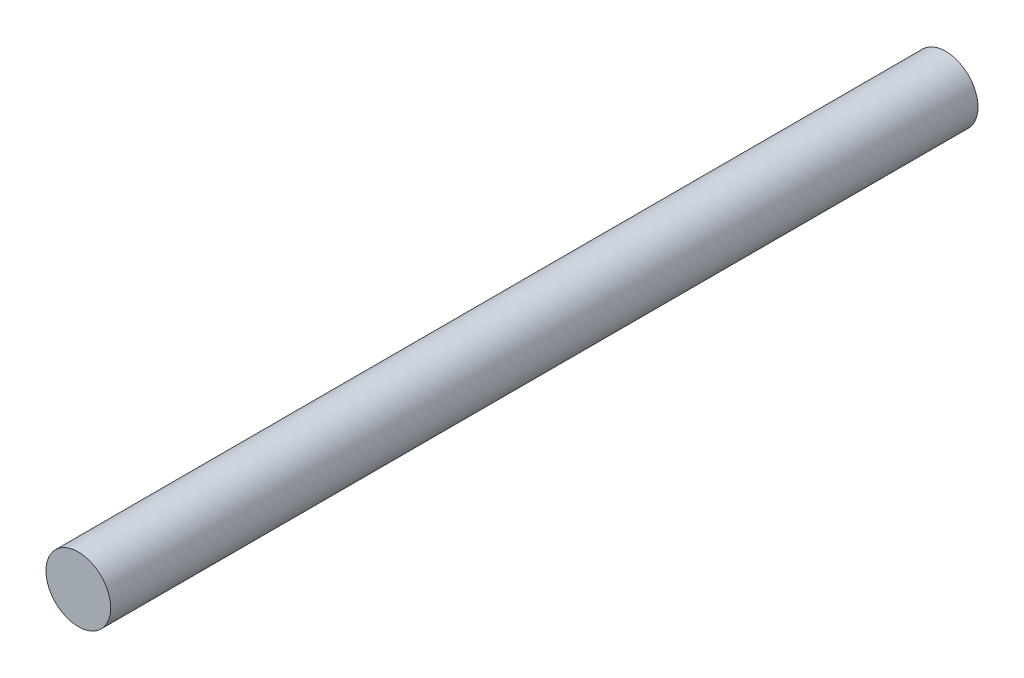
from build123d import *

# Parameters (mm, degrees)
ESTRUSIONE_ESTRUSIONE1_DEPTH      = 33.5
ESTRUSIONE_ESTRUSIONE1_DEPTH_BACK = 33.5
SCHIZZO1_R                        = 2.5


with BuildPart() as part:
    # Schizzo1 → Estrusione-Estrusione1 (new, two sides: drawn at the far end of the back side and taken through both)
    with BuildSketch(Plane.XY.offset(-ESTRUSIONE_ESTRUSIONE1_DEPTH_BACK)):
        Circle(SCHIZZO1_R)
    extrude(amount=ESTRUSIONE_ESTRUSIONE1_DEPTH + ESTRUSIONE_ESTRUSIONE1_DEPTH_BACK)


solid = part.part
